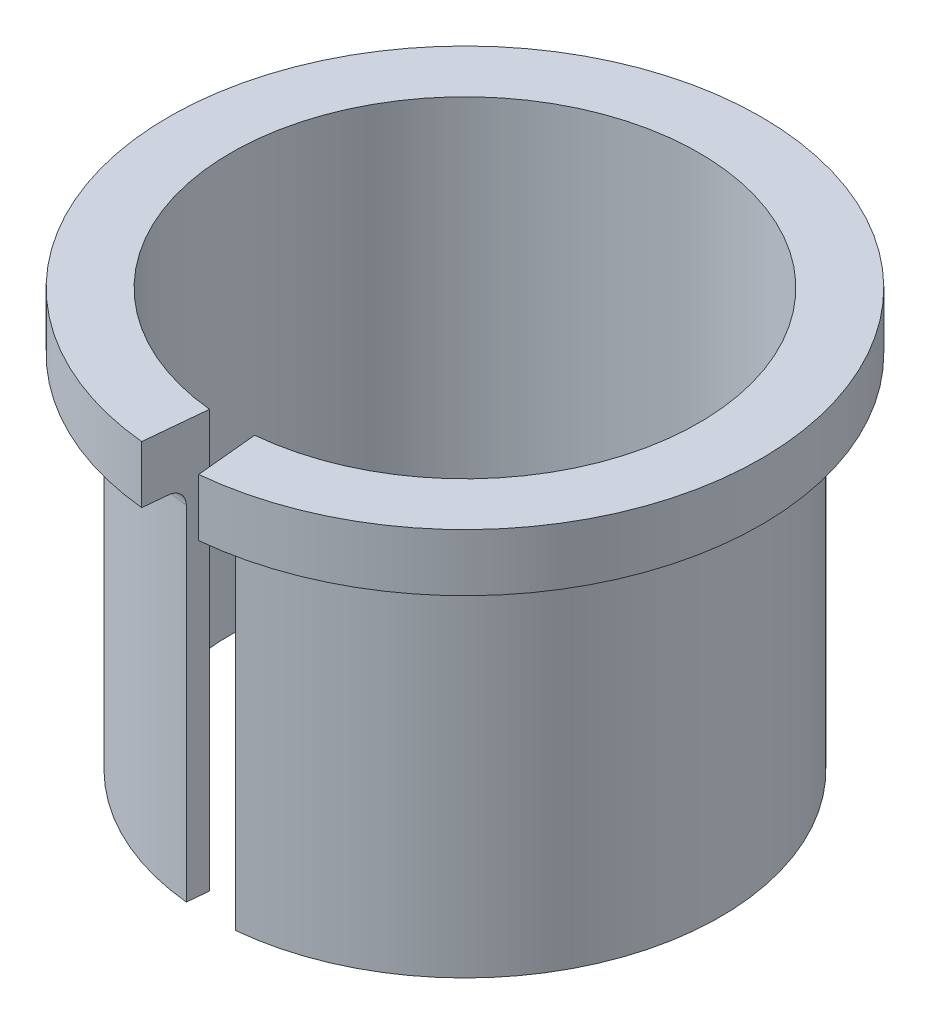
from build123d import *

# Parameters (mm, degrees)
SKETCH1_R           = 15.6
SKETCH1_R_2         = 14.3
BOSS_EXTRUDE1_DEPTH = 22
SKETCH2_R           = 18.1
SKETCH2_R_2         = 14.3
BOSS_EXTRUDE2_DEPTH = 3.5
FILLET1_R           = 1
CUT_EXTRUDE1_DEPTH  = 26.5


with BuildPart() as part:
    # Sketch1 → Boss-Extrude1 (new body)
    with BuildSketch(Plane(origin=(0, 0, 0), x_dir=(1, 0, 0), z_dir=(0, 1, 0))):
        Circle(SKETCH1_R)
        Circle(SKETCH1_R_2, mode=Mode.SUBTRACT)
    extrude(amount=BOSS_EXTRUDE1_DEPTH)

    # Sketch2 → Boss-Extrude2 (add)
    with BuildSketch(Plane(origin=(0, 22, 0), x_dir=(1, 0, 0), z_dir=(0, 1, 0))):
        Circle(SKETCH2_R)
        Circle(SKETCH2_R_2, mode=Mode.SUBTRACT)
    extrude(amount=BOSS_EXTRUDE2_DEPTH)

    # Fillet1
    fillet1_edges = [part.edges().sort_by_distance(p)[0] for p in [
        (-15.6, 22, 0),
    ]]
    fillet(fillet1_edges, radius=FILLET1_R)

    # Sketch3 → Cut-Extrude1 (cut, through all)
    with BuildSketch(Plane(origin=(0, 25.5, 0), x_dir=(1, 0, 0), z_dir=(0, 1, 0))):
        Polygon((0, 0), (-1.75, -18.1), (1.75, -18.1), align=None)
    extrude(amount=-CUT_EXTRUDE1_DEPTH, mode=Mode.SUBTRACT)


solid = part.part
